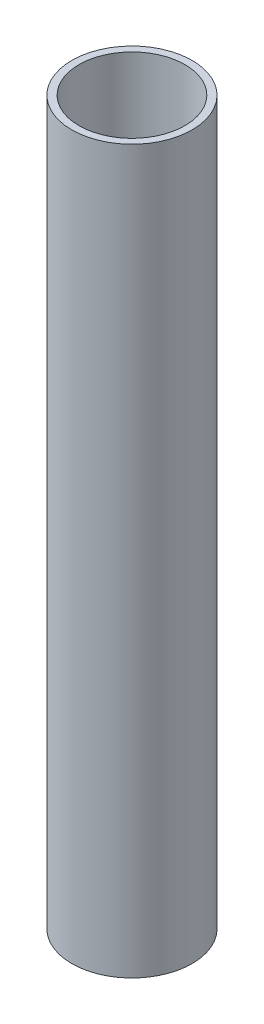
from build123d import *

# Parameters (mm, degrees)
SKETCH1_R           = 12.7
SKETCH1_R_2         = 11.176
BOSS_EXTRUDE1_DEPTH = 152.4


with BuildPart() as part:
    # Sketch1 → Boss-Extrude1 (new body)
    with BuildSketch(Plane(origin=(0, 0, 0), x_dir=(1, 0, 0), z_dir=(0, 1, 0))):
        Circle(SKETCH1_R)
        Circle(SKETCH1_R_2, mode=Mode.SUBTRACT)
    extrude(amount=BOSS_EXTRUDE1_DEPTH)


solid = part.part
